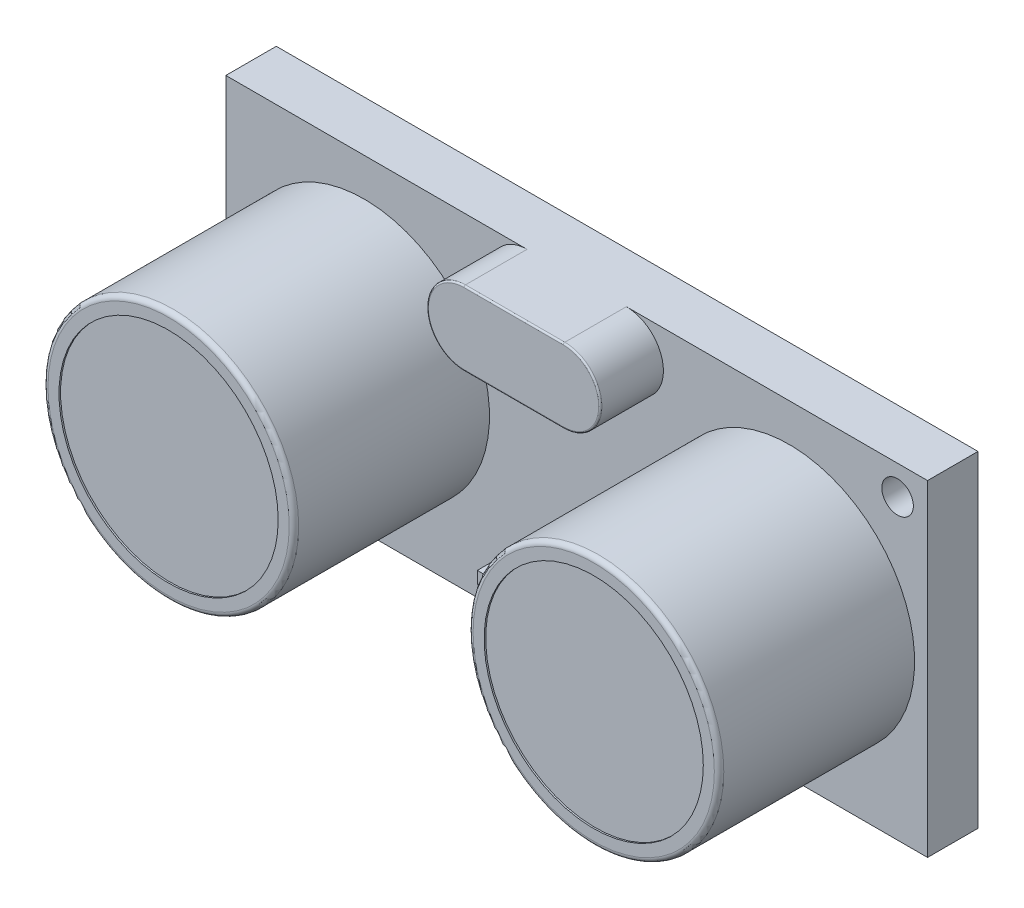
from build123d import *

# Parameters (mm, degrees)
SKETCH_1_W          = 44.5
SKETCH_1_H          = 20.7
EXTRUDE_1_DEPTH     = 3.2
EXTRUDE_2_DEPTH     = 4
FILLET_1_R          = 0.1
SKETCH_3_R          = 7.95
EXTRUDE_3_DEPTH     = 12.4
SKETCH_4_R          = 6.95
CUT_EXTRUDE_1_DEPTH = 0.1
FILLET_2_R          = 0.3
SKETCH_5_W          = 10.605065306
SKETCH_5_H          = 0.750801084
EXTRUDE_4_DEPTH     = 1
SKETCH_6_W          = 10.3
SKETCH_6_H          = 2.5
EXTRUDE_5_DEPTH     = 4.5
SKETCH_7_R          = 0.600934077
EXTRUDE_6_DEPTH     = 8
SKETCH_8_R          = 1
CUT_EXTRUDE_2_DEPTH = 10


with BuildPart() as part:
    # Эскиз1 → Бобышка-Вытянуть1 (new body)
    with BuildSketch(Plane.XY):
        Rectangle(SKETCH_1_W, SKETCH_1_H)
    extrude(amount=EXTRUDE_1_DEPTH)

    # Эскиз2 → Бобышка-Вытянуть2 (add)
    with BuildSketch(Plane.XY.offset(3.2)):
        with BuildLine():
            Line((-3.15, 10.35), (3.15, 10.35))
            ThreePointArc((3.15, 10.35), (5.5, 8), (3.15, 5.65))
            Line((3.15, 5.65), (-3.15, 5.65))
            ThreePointArc((-3.15, 5.65), (-5.5, 8), (-3.15, 10.35))
        make_face()
    extrude(amount=EXTRUDE_2_DEPTH)

    # Скругление1
    fillet_1_edges = [part.edges().sort_by_distance(p)[0] for p in [
        (-5.5, 8, 7.2),
        (0, 5.65, 7.2),
        (5.5, 8, 7.2),
        (0, 10.35, 7.2),
    ]]
    fillet(fillet_1_edges, radius=FILLET_1_R)

    # Эскиз3 → Бобышка-Вытянуть3 (add)
    with BuildSketch(Plane.XY.offset(3.2)):
        with Locations((-13.48, 0)):
            Circle(SKETCH_3_R)
        with Locations((13.48, 0)):
            Circle(SKETCH_3_R)
    extrude(amount=EXTRUDE_3_DEPTH)

    # Эскиз4 → Вырез-Вытянуть1 (cut)
    with BuildSketch(Plane.XY.offset(15.6)):
        with Locations((-13.48, 0)):
            Circle(SKETCH_4_R)
        with Locations((13.48, 0)):
            Circle(SKETCH_4_R)
    extrude(amount=-CUT_EXTRUDE_1_DEPTH, mode=Mode.SUBTRACT)

    # Скругление2
    fillet_2_edges = [part.edges().sort_by_distance(p)[0] for p in [
        (-21.43, 0, 15.6),
        (5.53, 0, 15.6),
    ]]
    fillet(fillet_2_edges, radius=FILLET_2_R)

    # Эскиз5 → Бобышка-Вытянуть4 (add)
    with BuildSketch(Plane.XY.offset(3.2)):
        with Locations((0, -8.235349386)):
            Rectangle(SKETCH_5_W, SKETCH_5_H)
    extrude(amount=EXTRUDE_4_DEPTH)

    # Эскиз8 → Вырез-Вытянуть2 (cut)
    with BuildSketch(Plane(origin=(0, 0, 0), x_dir=(-1, 0, 0), z_dir=(0, 0, -1))):
        with Locations((-20.35, 8.5)):
            Circle(SKETCH_8_R)
        with Locations((20.35, -8.5)):
            Circle(SKETCH_8_R)
    extrude(amount=-CUT_EXTRUDE_2_DEPTH, mode=Mode.SUBTRACT)


with BuildPart() as body_2:
    # Эскиз6 → Бобышка-Вытянуть5 (new body)
    with BuildSketch(Plane(origin=(0, 0, 0), x_dir=(-1, 0, 0), z_dir=(0, 0, -1))):
        with Locations((0, -9.1)):
            Rectangle(SKETCH_6_W, SKETCH_6_H)
    extrude(amount=EXTRUDE_5_DEPTH)

    # Эскиз7 → Бобышка-Вытянуть6 (add)
    with BuildSketch(Plane.XZ.offset(10.35)):
        with Locations((-3.894780621, -3.533075537)):
            Circle(SKETCH_7_R)
        with Locations((-1.394780621, -3.533075537)):
            Circle(SKETCH_7_R)
        with Locations((1.105219379, -3.533075537)):
            Circle(SKETCH_7_R)
        with Locations((3.605219379, -3.533075537)):
            Circle(SKETCH_7_R)
    extrude(amount=EXTRUDE_6_DEPTH)


solid = Compound([part.part, body_2.part])
